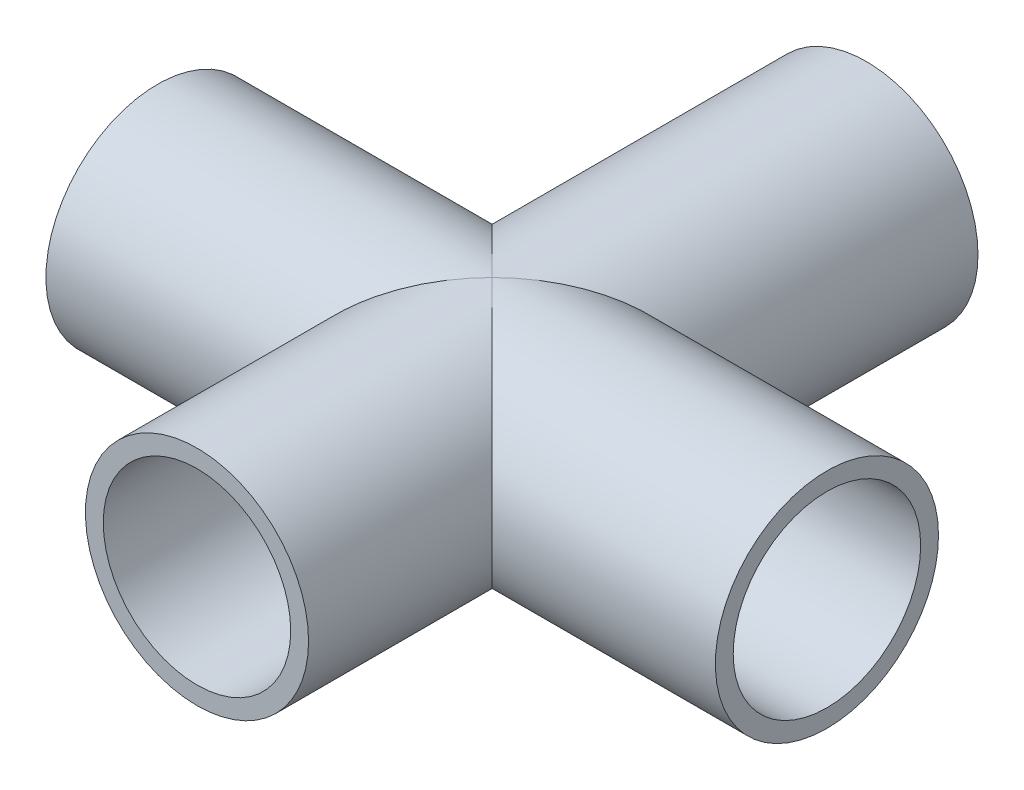
from build123d import *

# Parameters (mm, degrees)
SKETCH1_R           = 12.7
SKETCH1_R_2         = 10.668
BOSS_EXTRUDE1_DEPTH = 76.2
SKETCH2_R           = 12.7
SKETCH2_R_2         = 10.668
BOSS_EXTRUDE2_DEPTH = 38.1


with BuildPart() as part:
    # Sketch1 → Boss-Extrude1 (new body)
    with BuildSketch(Plane.XY):
        Circle(SKETCH1_R)
        Circle(SKETCH1_R_2, mode=Mode.SUBTRACT)
    extrude(amount=BOSS_EXTRUDE1_DEPTH)

    # Sketch2 → Boss-Extrude2 (add, symmetric)
    with BuildSketch(Plane(origin=(0, 0, 0), x_dir=(0, 0, -1), z_dir=(1, 0, 0))):
        with Locations((-42.5958, 0)):
            Circle(SKETCH2_R)
        with Locations((-42.5958, 0)):
            Circle(SKETCH2_R_2, mode=Mode.SUBTRACT)
    extrude(amount=BOSS_EXTRUDE2_DEPTH, both=True)


solid = part.part
